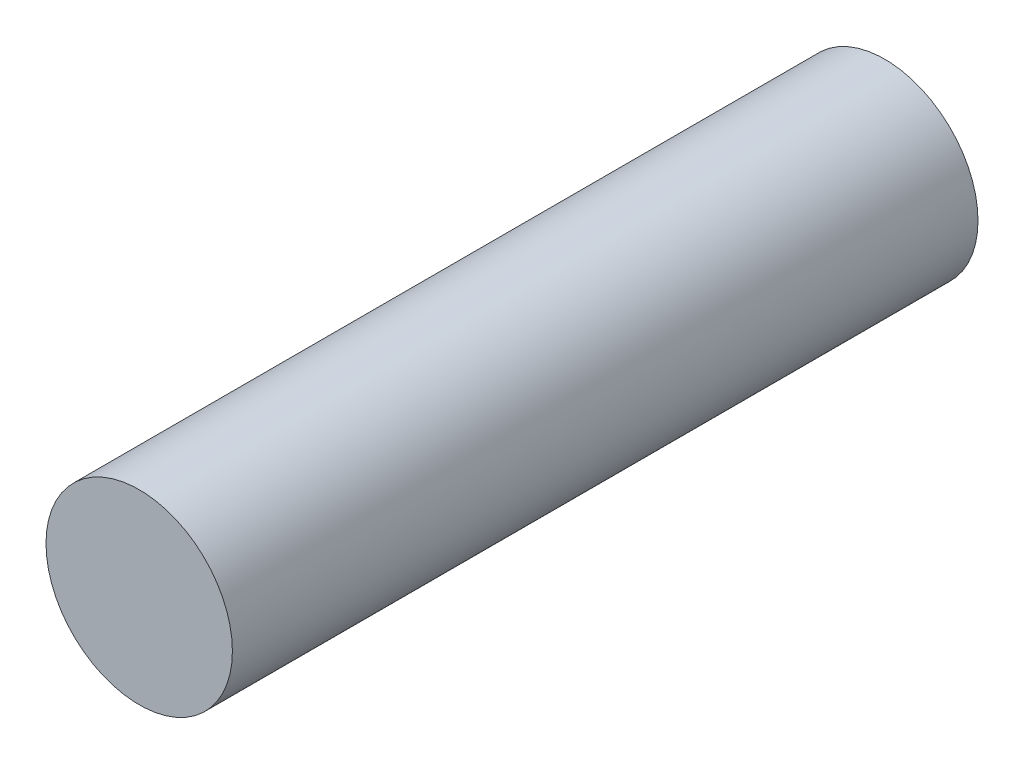
from build123d import *

# Parameters (mm, degrees)
SKETCH1_R          = 1
BASE_EXTRUDE_DEPTH = 8


with BuildPart() as part:
    # Sketch1 → Base-Extrude (new body)
    with BuildSketch(Plane.XY):
        Circle(SKETCH1_R)
    extrude(amount=BASE_EXTRUDE_DEPTH)


solid = part.part
